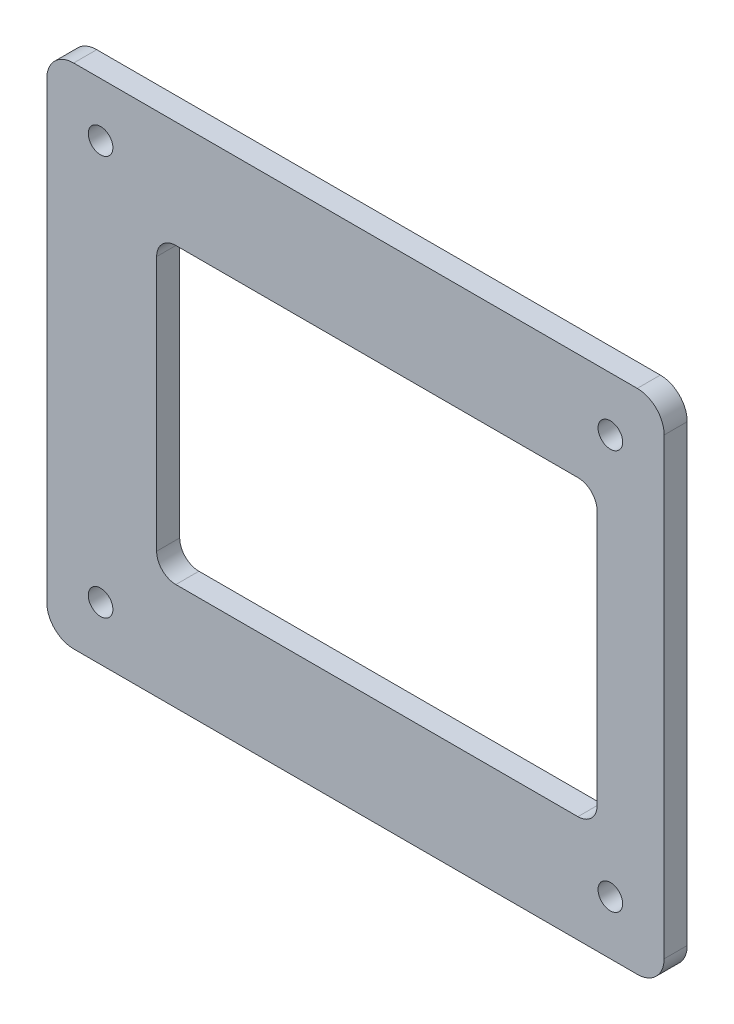
from build123d import *

# Parameters (mm, degrees)
SKETCH1_W                  = 80.3
SKETCH1_H                  = 66
BOSS_EXTRUDE1_DEPTH        = 3
F_3_2_3_2_DIAMETER_HOLE1_D = 3.2
SKETCH2_W                  = 57.29
SKETCH2_H                  = 38.19
CUT_EXTRUDE1_DEPTH         = 4
FILLET1_R                  = 3.5
FILLET2_R                  = 2.5


with BuildPart() as part:
    # Sketch1 → Boss-Extrude1 (new body)
    with BuildSketch(Plane.XY):
        with Locations((40.15, 33)):
            Rectangle(SKETCH1_W, SKETCH1_H)
    extrude(amount=BOSS_EXTRUDE1_DEPTH)

    # Ø3.2 (3.2) Diameter Hole1 (through all)
    with Locations(Plane.XY.offset(3)):
        with Locations((7, 59), (73.3, 59), (73.3, 7), (7, 7)):
            Hole(F_3_2_3_2_DIAMETER_HOLE1_D / 2)

    # Sketch2 → Cut-Extrude1 (cut, through all)
    with BuildSketch(Plane.XY.offset(3)):
        with Locations((42.935, 32.995)):
            Rectangle(SKETCH2_W, SKETCH2_H)
    extrude(amount=-CUT_EXTRUDE1_DEPTH, mode=Mode.SUBTRACT)

    # Fillet1
    fillet1_edges = [part.edges().sort_by_distance(p)[0] for p in [
        (0, 66, 1.5),
        (80.3, 66, 1.5),
        (80.3, 0, 1.5),
        (0, 0, 1.5),
    ]]
    fillet(fillet1_edges, radius=FILLET1_R)

    # Fillet2
    fillet2_edges = [part.edges().sort_by_distance(p)[0] for p in [
        (14.29, 13.9, 1.5),
        (14.29, 52.09, 1.5),
        (71.58, 52.09, 1.5),
        (71.58, 13.9, 1.5),
    ]]
    fillet(fillet2_edges, radius=FILLET2_R)


solid = part.part
